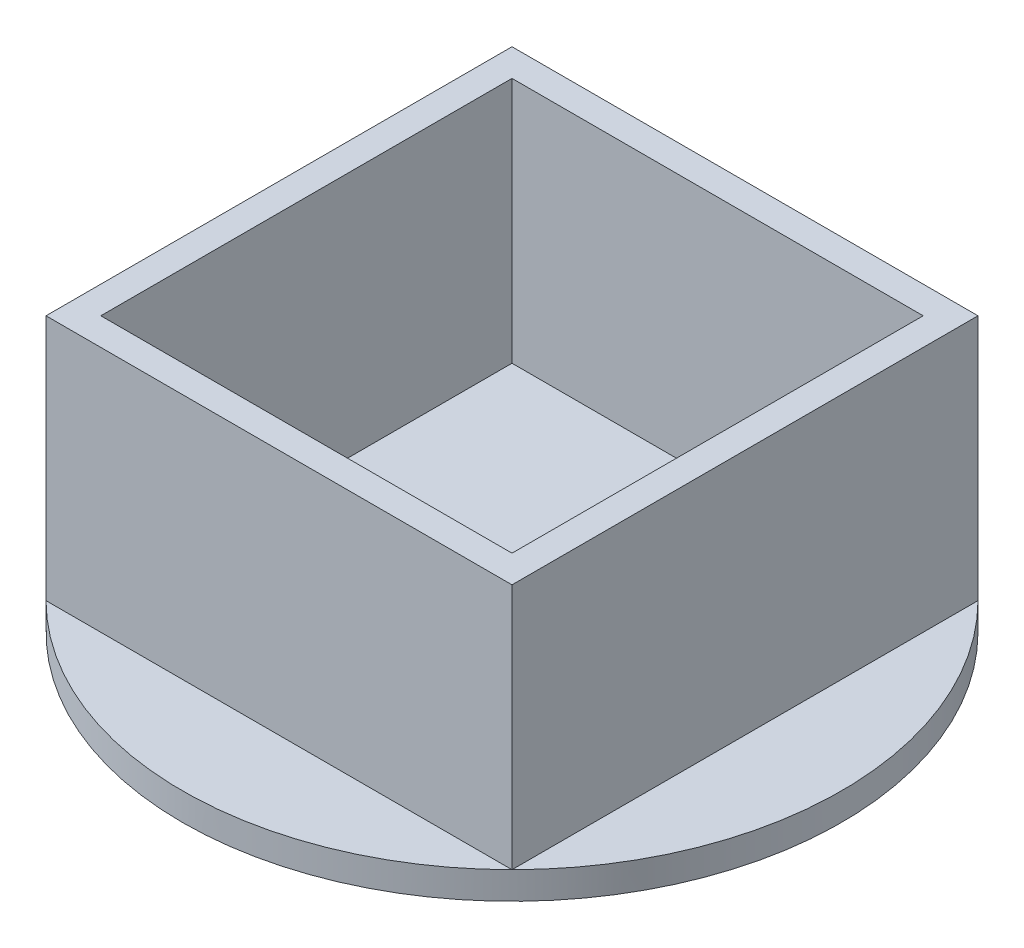
from build123d import *

# Parameters (mm, degrees)
SKETCH1_W           = 17
SKETCH1_H           = 17
SKETCH1_W_2         = 15
SKETCH1_H_2         = 15
EXTRUDE_THIN1_DEPTH = 10
SKETCH2_R           = 12.02081528
BOSS_EXTRUDE1_DEPTH = 1


with BuildPart() as part:
    # Sketch1 → Extrude-Thin1 (new body)
    with BuildSketch(Plane(origin=(0, 0, 0), x_dir=(1, 0, 0), z_dir=(0, 1, 0))):
        Rectangle(SKETCH1_W, SKETCH1_H)
        Rectangle(SKETCH1_W_2, SKETCH1_H_2, mode=Mode.SUBTRACT)
    extrude(amount=EXTRUDE_THIN1_DEPTH)

    # Sketch2 → Boss-Extrude1 (add)
    with BuildSketch(Plane(origin=(0, 0, 0), x_dir=(1, 0, 0), z_dir=(0, 1, 0))):
        Circle(SKETCH2_R)
    extrude(amount=BOSS_EXTRUDE1_DEPTH)


solid = part.part
